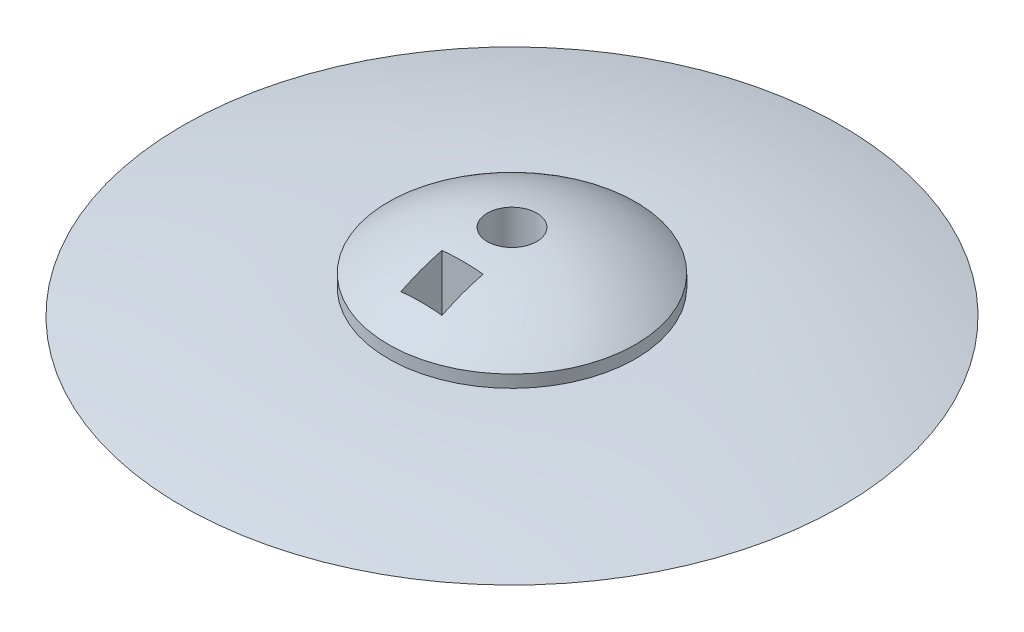
from build123d import *

# Parameters (mm, degrees)
SKETCH2_R          = 3.81
SKETCH2_W          = 6.35
SKETCH2_H          = 6.35
CUT_EXTRUDE1_DEPTH = 20.05


with BuildPart() as part:
    # Sketch1 → Revolve1 (revolve)
    with BuildSketch(Plane.XY):
        with BuildLine():
            Line((0, 0), (0, 19.05))
            ThreePointArc((0, 19.05), (10.040231571, 17.420694713), (19.05, 12.7))
            Line((19.05, 12.7), (19.05, 10.795))
            ThreePointArc((19.05, 10.795), (35.038891456, 9.839095469), (50.8, 6.985))
            ThreePointArc((50.8, 6.985), (35.038891456, 4.130904531), (19.05, 3.175))
            Line((19.05, 3.175), (19.05, 1.27))
            ThreePointArc((19.05, 1.27), (10.801103513, 0.793808666), (2.54, 0.635))
            Line((2.54, 0.635), (2.54, 0))
            Line((2.54, 0), (0, 0))
        make_face()
    revolve(axis=Axis((0, 0, 0), (0, 1, 0)))

    # Sketch2 → Cut-Extrude1 (cut, through all)
    with BuildSketch(Plane.XZ):
        Circle(SKETCH2_R)
        with Locations((0, 10.795)):
            Rectangle(SKETCH2_W, SKETCH2_H)
    extrude(amount=-CUT_EXTRUDE1_DEPTH, mode=Mode.SUBTRACT)

    # Sketch3 → Revolve4 (revolve)
    with BuildSketch(Plane(origin=(0, 5.08, 0), x_dir=(1, 0, 0), z_dir=(0, 1, 0))):
        with BuildLine():
            Line((0, -1.905), (0, -5.715))
            ThreePointArc((0, -5.715), (1.905, -3.81), (0, -1.905))
        make_face()
    revolve(axis=Axis((0, 5.08, 1.905), (0, 0, 1)))


solid = part.part
